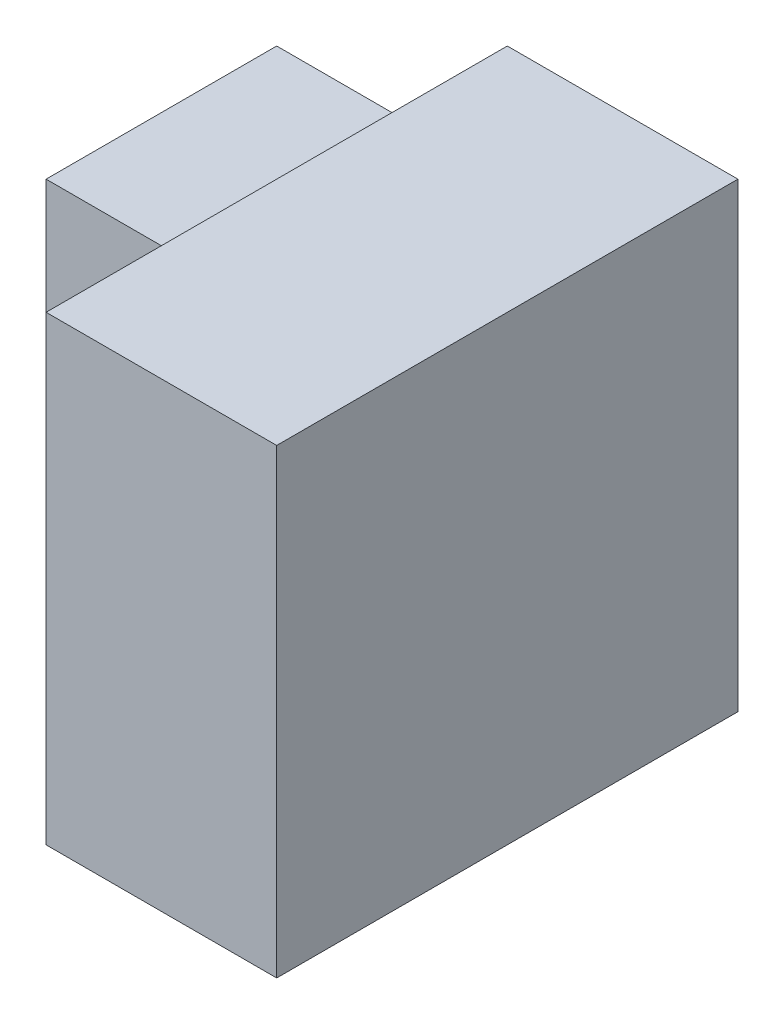
from build123d import *

# Parameters (mm, degrees)
SKETCH1_W           = 4
SKETCH1_H           = 4
BOSS_EXTRUDE1_DEPTH = 2
SKETCH2_W           = 2
SKETCH2_H           = 3
BOSS_EXTRUDE2_DEPTH = 2
CUT_EXTRUDE1_DEPTH  = 2


with BuildPart() as part:
    # Sketch1 → Boss-Extrude1 (new body)
    with BuildSketch(Plane(origin=(0, 0, 0), x_dir=(0, 0, -1), z_dir=(1, 0, 0))):
        with Locations((2, 2)):
            Rectangle(SKETCH1_W, SKETCH1_H)
    extrude(amount=BOSS_EXTRUDE1_DEPTH)

    # Sketch2 → Boss-Extrude2 (add)
    with BuildSketch(Plane.ZY):
        with Locations((-3, 1.5)):
            Rectangle(SKETCH2_W, SKETCH2_H)
    extrude(amount=BOSS_EXTRUDE2_DEPTH)

    # Sketch3 → Cut-Extrude1 (cut)
    with BuildSketch(Plane.ZY.offset(2)):
        Polygon((-2, 0), (-4, 3), (-4, 0), align=None)
    extrude(amount=-CUT_EXTRUDE1_DEPTH, mode=Mode.SUBTRACT)


solid = part.part
